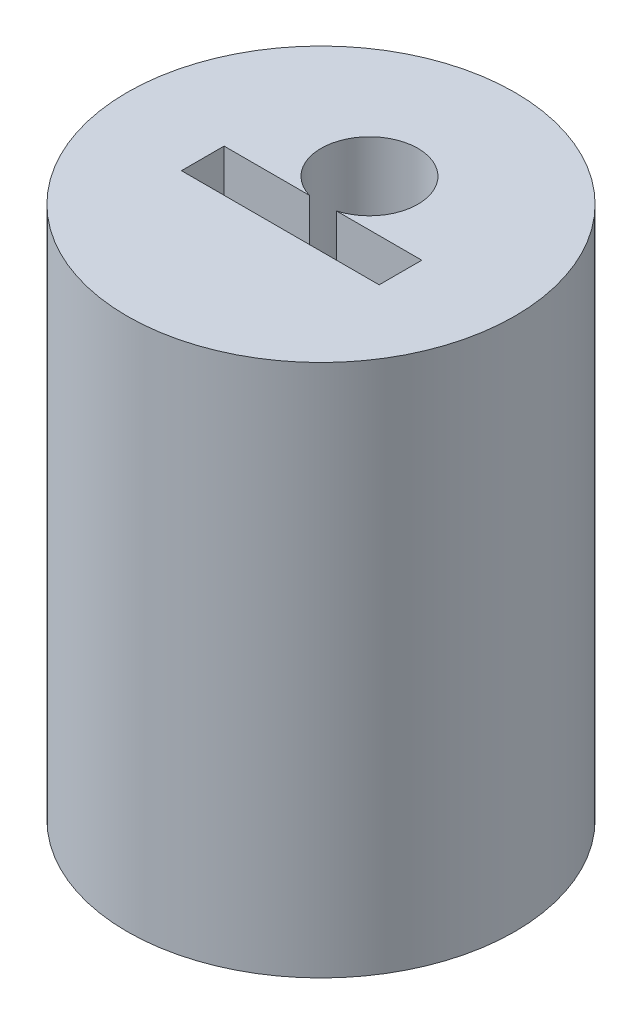
from build123d import *

# Parameters (mm, degrees)
SKETCH1_R           = 1
BOSS_EXTRUDE1_DEPTH = 1.25
SKETCH3_R           = 1
BOSS_EXTRUDE2_DEPTH = 0.25


with BuildPart() as part:
    # Sketch1 → Boss-Extrude1 (new body, symmetric)
    with BuildSketch(Plane(origin=(0, 0, 0), x_dir=(1, 0, 0), z_dir=(0, 1, 0))):
        Circle(SKETCH1_R)
        with BuildLine():
            Line((-0.51, -0.21), (0.51, -0.21))
            Line((0.51, -0.21), (0.51, 0.01))
            Line((0.51, 0.01), (0.07, 0.01))
            ThreePointArc((0.07, 0.01), (0, 0.5), (-0.07, 0.01))
            Line((-0.07, 0.01), (-0.51, 0.01))
            Line((-0.51, 0.01), (-0.51, -0.21))
        make_face(mode=Mode.SUBTRACT)
    extrude(amount=BOSS_EXTRUDE1_DEPTH, both=True)

    # Sketch3 → Boss-Extrude2 (add)
    with BuildSketch(Plane.XZ.offset(1.25)):
        Circle(SKETCH3_R)
    extrude(amount=BOSS_EXTRUDE2_DEPTH)


solid = part.part
